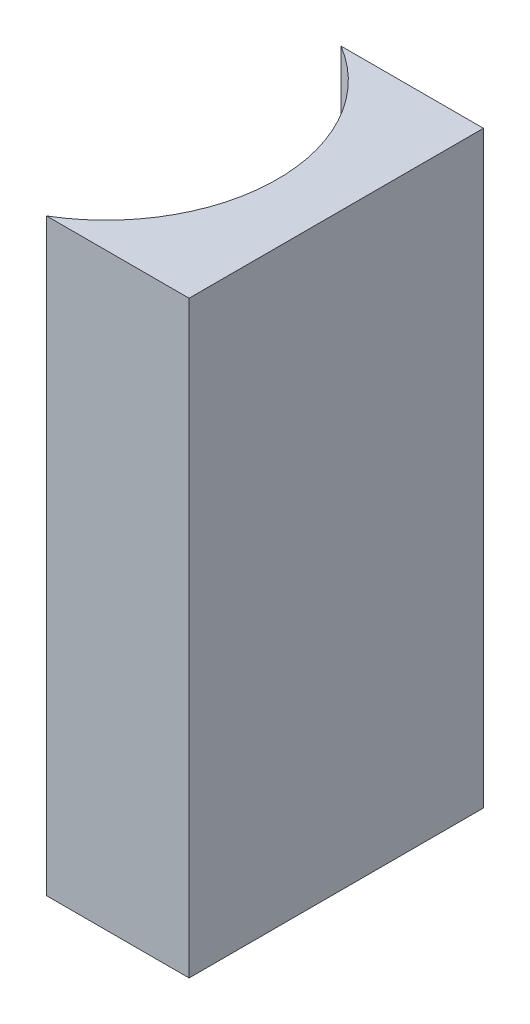
from build123d import *

# Parameters (mm, degrees)
EXTRUDE_1_DEPTH = 20


with BuildPart() as part:
    # 草图1 → 凸台-拉伸1 (new body)
    with BuildSketch(Plane(origin=(0, 0, 0), x_dir=(1, 0, 0), z_dir=(0, 1, 0))):
        with BuildLine():
            Line((0, 0), (0, -10))
            Line((0, -10), (-4.841342584, -10))
            ThreePointArc((-4.841342584, -10), (-2, -5), (-4.841342584, 0))
            Line((-4.841342584, 0), (0, 0))
        make_face()
    extrude(amount=EXTRUDE_1_DEPTH)


solid = part.part
